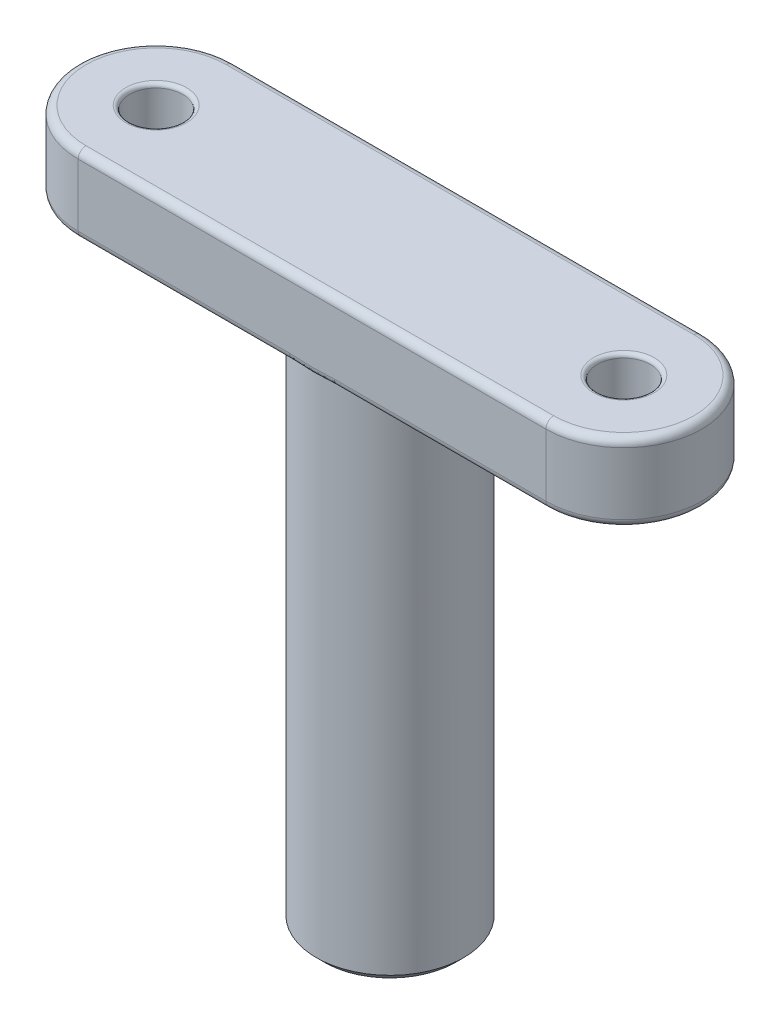
from build123d import *

# Parameters (mm, degrees)
BOSS_EXTRUDE1_DEPTH      = 5
M3_CLEARANCE_HOLE1_D     = 3.4
M3_CLEARANCE_HOLE1_DEPTH = 5
M3_CLEARANCE_HOLE1_TIP   = 1.021463052
SKETCH4_R                = 4.725
BOSS_EXTRUDE2_DEPTH      = 33
SKETCH5_R                = 3.025
CUT_EXTRUDE1_DEPTH       = 2
FILLET1_R                = 0.5
CHAMFER1_SIZE            = 0.5
FILLET2_R                = 0.25


with BuildPart() as part:
    # Sketch1 → Boss-Extrude1 (new body)
    with BuildSketch(Plane(origin=(0, 0, 0), x_dir=(1, 0, 0), z_dir=(0, 1, 0))):
        with BuildLine():
            Line((-15, 5), (15, 5))
            ThreePointArc((15, 5), (20, 0), (15, -5))
            Line((15, -5), (-15, -5))
            ThreePointArc((-15, -5), (-20, 0), (-15, 5))
        make_face()
    extrude(amount=BOSS_EXTRUDE1_DEPTH)

    # M3 Clearance Hole1
    with Locations(Plane(origin=(0, 5, 0), x_dir=(1, 0, 0), z_dir=(0, 1, 0))):
        with Locations((-15, 0), (15, 0)):
            Hole(M3_CLEARANCE_HOLE1_D / 2, depth=M3_CLEARANCE_HOLE1_DEPTH)
            with Locations((0, 0, -(M3_CLEARANCE_HOLE1_DEPTH + M3_CLEARANCE_HOLE1_TIP / 2))):  # 118° drill point
                Cone(0, M3_CLEARANCE_HOLE1_D / 2, M3_CLEARANCE_HOLE1_TIP, mode=Mode.SUBTRACT)

    # Sketch4 → Boss-Extrude2 (add)
    with BuildSketch(Plane.XZ):
        Circle(SKETCH4_R)
    extrude(amount=BOSS_EXTRUDE2_DEPTH)

    # Sketch5 → Cut-Extrude1 (cut)
    with BuildSketch(Plane.XZ.offset(33)):
        Circle(SKETCH5_R)
    extrude(amount=-CUT_EXTRUDE1_DEPTH, mode=Mode.SUBTRACT)

    # Fillet1
    fillet1_edges = [part.edges().sort_by_distance(p)[0] for p in [
        (20, 5, 0),
        (0, 5, -5),
        (-20, 5, 0),
        (0, 0, -5),
        (20, 0, 0),
        (0, 0, 5),
        (-20, 0, 0),
        (0, 5, 5),
    ]]
    fillet(fillet1_edges, radius=FILLET1_R)

    # Chamfer1
    chamfer1_edges = [part.edges().sort_by_distance(p)[0] for p in [
        (-4.725, -33, 0),
    ]]
    chamfer(chamfer1_edges, length=CHAMFER1_SIZE)

    # Fillet2
    fillet2_edges = [part.edges().sort_by_distance(p)[0] for p in [
        (16.7, 5, 0),
        (-13.3, 5, 0),
    ]]
    fillet(fillet2_edges, radius=FILLET2_R)


solid = part.part
